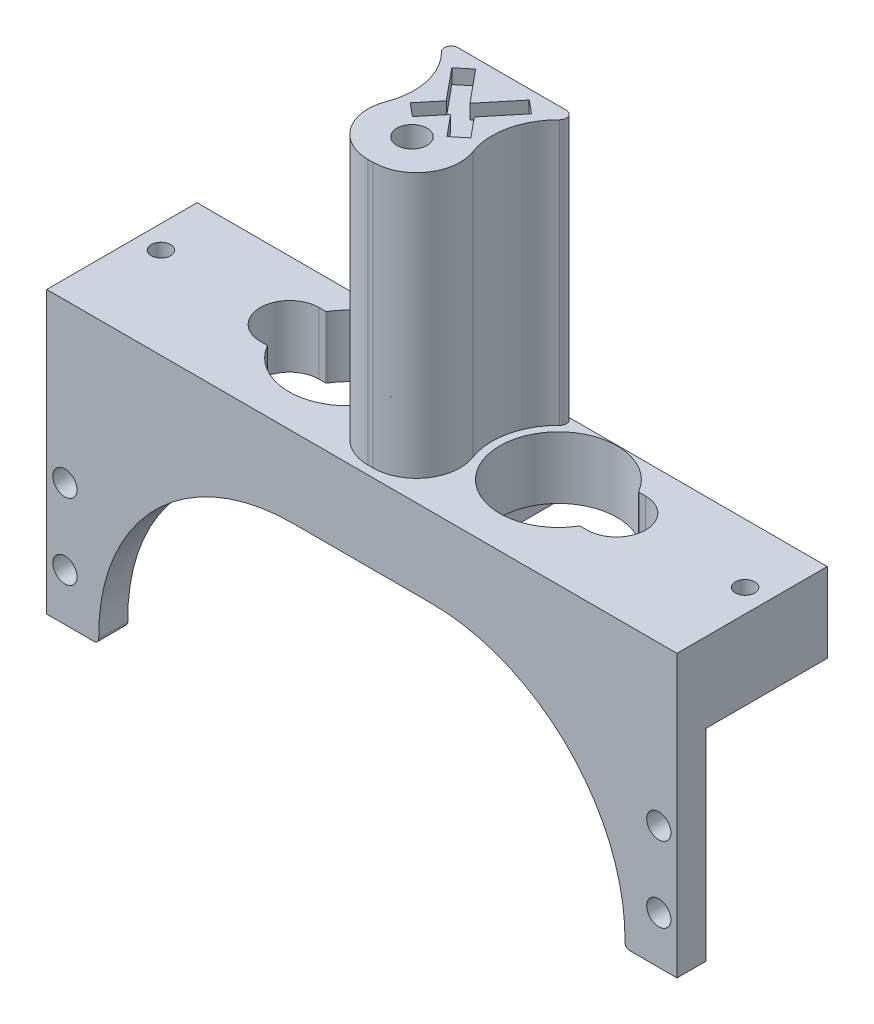
from build123d import *

# Parameters (mm, degrees)
BOSS_EXTRUDE1_START = -1.8
SKETCH1_R           = 1
BOSS_EXTRUDE1_DEPTH = 1.8
BOSS_EXTRUDE2_START = -1.8
SKETCH1_5_R         = 1
SKETCH1_5_W         = 23.35
SKETCH1_5_H         = 12.5
SKETCH1_5_W_2       = 0.2
SKETCH1_5_H_2       = 11.7
BOSS_EXTRUDE2_DEPTH = 6.4
SKETCH1_6_R         = 1
CUT_EXTRUDE9_DEPTH  = 5.25
SKETCH6_R           = 1.25
BOSS_EXTRUDE4_DEPTH = 3
CUT_EXTRUDE6_START  = -8.2
SKETCH4_6_R         = 1.55
CUT_EXTRUDE6_DEPTH  = 5.2
BOSS_EXTRUDE3_DEPTH = 27.3
CUT_EXTRUDE7_START  = -3
SKETCH4_7_R         = 1.55
CUT_EXTRUDE7_DEPTH  = 30.3
CUT_EXTRUDE8_DEPTH  = 1.5


with BuildPart() as part:
    # Sketch1 → Boss-Extrude1 (new body)
    with BuildSketch(Plane.XZ.offset(10.394345176).offset(BOSS_EXTRUDE1_START)):
        Polygon((-30.246052812, 14.536068682), (-30.246052812, -0.963931318), (-25.671052812, -0.963931318), (-25.671052812, 11.536068682), (-2.321052812, 11.536068682), (-2.321052812, -0.963931318), (6.828947188, -0.963931318), (6.828947188, 11.536068682), (30.178947188, 11.536068682), (30.178947188, -0.963931318), (34.753947188, -0.963931318), (34.753947188, 14.536068682), align=None)
        with Locations((-27.871052812, 5.136068682)):
            Circle(SKETCH1_R, mode=Mode.SUBTRACT)
        with Locations((32.378947188, 5.136068682)):
            Circle(SKETCH1_R, mode=Mode.SUBTRACT)
    extrude(amount=BOSS_EXTRUDE1_DEPTH)

    # Sketch1_5 → Boss-Extrude2 (add)
    with BuildSketch(Plane.XZ.offset(10.394345176).offset(BOSS_EXTRUDE2_START)):
        with BuildLine():
            Line((-30.246052812, 14.536068682), (-30.246052812, -0.963931318))
            Line((-30.246052812, -0.963931318), (-25.671052812, -0.963931318))
            Line((-25.671052812, -0.963931318), (-25.671052812, -0.713931318))
            Line((-25.671052812, -0.713931318), (-29.746052812, -0.713931318))
            ThreePointArc((-29.746052812, -0.713931318), (-29.922829508, -0.640708013), (-29.996052812, -0.463931318))
            Line((-29.996052812, -0.463931318), (-29.996052812, 4.511068682))
            Line((-29.996052812, 4.511068682), (-28.651677562, 4.511068682))
            ThreePointArc((-28.651677562, 4.511068682), (-28.871052812, 5.136068682), (-28.651677562, 5.761068682))
            Line((-28.651677562, 5.761068682), (-29.996052812, 5.761068682))
            Line((-29.996052812, 5.761068682), (-29.996052812, 10.736068682))
            ThreePointArc((-29.996052812, 10.736068682), (-29.922829508, 10.912845377), (-29.746052812, 10.986068682))
            Line((-29.746052812, 10.986068682), (-25.671052812, 10.986068682))
            Line((-25.671052812, 10.986068682), (-25.671052812, 11.536068682))
            Line((-25.671052812, 11.536068682), (-2.321052812, 11.536068682))
            Line((-2.321052812, 11.536068682), (-2.321052812, -0.963931318))
            Line((-2.321052812, -0.963931318), (6.828947188, -0.963931318))
            Line((6.828947188, -0.963931318), (6.828947188, 11.536068682))
            Line((6.828947188, 11.536068682), (30.178947188, 11.536068682))
            Line((30.178947188, 11.536068682), (30.178947188, -0.963931318))
            Line((30.178947188, -0.963931318), (34.753947188, -0.963931318))
            Line((34.753947188, -0.963931318), (34.753947188, 14.536068682))
            Line((34.753947188, 14.536068682), (2.253947188, 14.536068682))
            Line((2.253947188, 14.536068682), (-30.246052812, 14.536068682))
        make_face()
        with Locations((-0.121052812, 5.136068682)):
            Circle(SKETCH1_5_R, mode=Mode.SUBTRACT)
        with Locations((4.628947188, 5.136068682)):
            Circle(SKETCH1_5_R, mode=Mode.SUBTRACT)
        with Locations((32.378947188, 5.136068682)):
            Circle(SKETCH1_5_R, mode=Mode.SUBTRACT)
        with Locations((18.503947188, 5.286068682)):
            Rectangle(SKETCH1_5_W, SKETCH1_5_H)
        with BuildLine():
            Line((19.103947188, 2.111068682), (18.425821266, 2.111068682))
            ThreePointArc((18.425821266, 2.111068682), (18.376229436, 2.097905601), (18.339693232, 2.06188169))
            ThreePointArc((18.339693232, 2.06188169), (7.078947188, 5.136068682), (18.339693232, 8.210255674))
            ThreePointArc((18.339693232, 8.210255674), (18.376229436, 8.174231764), (18.425821266, 8.161068682))
            Line((18.425821266, 8.161068682), (19.103947188, 8.161068682))
            ThreePointArc((19.103947188, 8.161068682), (22.128947188, 5.136068682), (19.103947188, 2.111068682))
        make_face(mode=Mode.SUBTRACT)
        Polygon((-25.671052812, -0.713931318), (-25.671052812, -0.963931318), (-2.321052812, -0.963931318), (-2.321052812, 11.536068682), (-25.671052812, 11.536068682), (-25.671052812, 10.986068682), (-25.471052812, 10.986068682), (-25.471052812, -0.713931318), align=None)
        with BuildLine():
            ThreePointArc((-13.831798857, 2.06188169), (-13.868335061, 2.097905601), (-13.917926891, 2.111068682))
            Line((-13.917926891, 2.111068682), (-14.596052812, 2.111068682))
            ThreePointArc((-14.596052812, 2.111068682), (-17.621052812, 5.136068682), (-14.596052812, 8.161068682))
            Line((-14.596052812, 8.161068682), (-13.917926891, 8.161068682))
            ThreePointArc((-13.917926891, 8.161068682), (-13.868335061, 8.174231764), (-13.831798857, 8.210255674))
            ThreePointArc((-13.831798857, 8.210255674), (-2.571052812, 5.136068682), (-13.831798857, 2.06188169))
        make_face(mode=Mode.SUBTRACT)
        with BuildLine():
            Line((-29.746052812, -0.713931318), (-25.671052812, -0.713931318))
            Line((-25.671052812, -0.713931318), (-25.671052812, 10.986068682))
            Line((-25.671052812, 10.986068682), (-29.746052812, 10.986068682))
            ThreePointArc((-29.746052812, 10.986068682), (-29.922829508, 10.912845377), (-29.996052812, 10.736068682))
            Line((-29.996052812, 10.736068682), (-29.996052812, 5.761068682))
            Line((-29.996052812, 5.761068682), (-28.651677562, 5.761068682))
            ThreePointArc((-28.651677562, 5.761068682), (-27.539861591, 6.079632339), (-26.871052812, 5.136068682))
            ThreePointArc((-26.871052812, 5.136068682), (-27.539861591, 4.192505025), (-28.651677562, 4.511068682))
            Line((-28.651677562, 4.511068682), (-29.996052812, 4.511068682))
            Line((-29.996052812, 4.511068682), (-29.996052812, -0.463931318))
            ThreePointArc((-29.996052812, -0.463931318), (-29.922829508, -0.640708013), (-29.746052812, -0.713931318))
        make_face()
        with Locations((-25.571052812, 5.136068682)):
            Rectangle(SKETCH1_5_W_2, SKETCH1_5_H_2)
        with Locations((4.628947188, 5.136068682)):
            Circle(SKETCH1_5_R)
        with Locations((-0.121052812, 5.136068682)):
            Circle(SKETCH1_5_R)
    extrude(amount=-BOSS_EXTRUDE2_DEPTH)

    # Sketch1_6 → Cut-Extrude9 (cut)
    with BuildSketch(Plane.XZ.offset(10.394345176)):
        with Locations((4.628947188, 5.136068682)):
            Circle(SKETCH1_6_R)
        with Locations((-0.121052812, 5.136068682)):
            Circle(SKETCH1_6_R)
    extrude(amount=-CUT_EXTRUDE9_DEPTH, mode=Mode.SUBTRACT)

    # Sketch6 → Boss-Extrude4 (add)
    with BuildSketch(Plane.XY.offset(14.536068682)):
        with BuildLine():
            Line((34.753947188, -10.394345176), (9.394953593, -10.394345176))
            ThreePointArc((9.394953593, -10.394345176), (23.644922083, -16.360870979), (29.392610104, -30.700505374))
            ThreePointArc((29.392610104, -30.700505374), (29.532392174, -31.049241035), (29.878947188, -31.194345176))
            Line((29.878947188, -31.194345176), (34.753947188, -31.194345176))
            Line((34.753947188, -31.194345176), (34.753947188, -10.394345176))
        make_face()
        with Locations((32.878947188, -26.30759383)):
            Circle(SKETCH6_R, mode=Mode.SUBTRACT)
        with Locations((32.878947188, -18.534091138)):
            Circle(SKETCH6_R, mode=Mode.SUBTRACT)
        with BuildLine():
            Line((-4.887059217, -10.394345176), (-30.246052812, -10.394345176))
            Line((-30.246052812, -10.394345176), (-30.246052812, -16.729871547))
            Line((-30.246052812, -16.729871547), (-28.371052812, -15.647339792))
            Line((-28.371052812, -15.647339792), (-25.871052812, -17.090715465))
            Line((-25.871052812, -17.090715465), (-25.871052812, -19.977466811))
            Line((-25.871052812, -19.977466811), (-28.371052812, -21.420842484))
            Line((-28.371052812, -21.420842484), (-30.246052812, -20.338310729))
            Line((-30.246052812, -20.338310729), (-30.246052812, -24.503374239))
            Line((-30.246052812, -24.503374239), (-28.371052812, -23.420842484))
            Line((-28.371052812, -23.420842484), (-25.871052812, -24.864218157))
            Line((-25.871052812, -24.864218157), (-25.871052812, -27.750969503))
            Line((-25.871052812, -27.750969503), (-28.371052812, -29.194345176))
            Line((-28.371052812, -29.194345176), (-30.246052812, -28.111813421))
            Line((-30.246052812, -28.111813421), (-30.246052812, -31.194345176))
            Line((-30.246052812, -31.194345176), (-25.371052812, -31.194345176))
            ThreePointArc((-25.371052812, -31.194345176), (-25.024497799, -31.049241035), (-24.884715729, -30.700505374))
            ThreePointArc((-24.884715729, -30.700505374), (-19.137027708, -16.360870979), (-4.887059217, -10.394345176))
        make_face()
        Polygon((-28.371052812, -23.420842484), (-30.246052812, -24.503374239), (-30.246052812, -28.111813421), (-28.371052812, -29.194345176), (-25.871052812, -27.750969503), (-25.871052812, -24.864218157), align=None)
        with Locations((-28.371052812, -26.30759383)):
            Circle(SKETCH6_R, mode=Mode.SUBTRACT)
        Polygon((-28.371052812, -15.647339792), (-30.246052812, -16.729871547), (-30.246052812, -20.338310729), (-28.371052812, -21.420842484), (-25.871052812, -19.977466811), (-25.871052812, -17.090715465), align=None)
        with Locations((-28.371052812, -18.534091138)):
            Circle(SKETCH6_R, mode=Mode.SUBTRACT)
    extrude(amount=-BOSS_EXTRUDE4_DEPTH)

    # Sketch4_6 → Cut-Extrude6 (cut)
    with BuildSketch(Plane(origin=(0, -2.194345176, 0), x_dir=(1, 0, 0), z_dir=(0, 1, 0)).offset(CUT_EXTRUDE6_START)):
        Polygon((5.103947188, -11.010607671), (5.103947188, -7.719711137), (2.253947188, -6.07426287), (-0.596052812, -7.719711137), (-0.596052812, -11.010607671), (2.253947188, -12.656055938), align=None)
        with Locations((2.253947188, -9.365159404)):
            Circle(SKETCH4_6_R, mode=Mode.SUBTRACT)
        with Locations((2.253947188, -9.365159404)):
            Circle(SKETCH4_6_R)
    extrude(amount=CUT_EXTRUDE6_DEPTH, mode=Mode.SUBTRACT)

    # Sketch4 → Boss-Extrude3 (add)
    with BuildSketch(Plane(origin=(0, -2.194345176, 0), x_dir=(1, 0, 0), z_dir=(0, 1, 0))):
        with BuildLine():
            Line((1.993192449, -13.656055938), (2.514701927, -13.656055938))
            ThreePointArc((2.514701927, -13.656055938), (6.217553798, -11.71318089), (6.722992999, -7.562228392))
            ThreePointArc((6.722992999, -7.562228392), (6.440270151, -3.658198764), (8.34156903, -0.236730934))
            ThreePointArc((8.34156903, -0.236730934), (8.500600778, 0.528068047), (7.852347904, 0.963931318))
            Line((7.852347904, 0.963931318), (-3.344453529, 0.963931318))
            ThreePointArc((-3.344453529, 0.963931318), (-3.992706402, 0.528068047), (-3.833674654, -0.236730934))
            ThreePointArc((-3.833674654, -0.236730934), (-1.932375775, -3.658198764), (-2.215098624, -7.562228392))
            ThreePointArc((-2.215098624, -7.562228392), (-1.709659423, -11.71318089), (1.993192449, -13.656055938))
        make_face()
    extrude(amount=BOSS_EXTRUDE3_DEPTH)

    # Sketch4_7 → Cut-Extrude7 (cut)
    with BuildSketch(Plane(origin=(0, -2.194345176, 0), x_dir=(1, 0, 0), z_dir=(0, 1, 0)).offset(CUT_EXTRUDE7_START)):
        with Locations((2.253947188, -9.365159404)):
            Circle(SKETCH4_7_R)
    extrude(amount=CUT_EXTRUDE7_DEPTH, mode=Mode.SUBTRACT)

    # Sketch5 → Cut-Extrude8 (cut)
    with BuildSketch(Plane(origin=(0, 25.105654824, 0), x_dir=(1, 0, 0), z_dir=(0, 1, 0))):
        Polygon((5.385896038, -6.427447361), (3.697691675, -4.382517944), (6.366164089, -1.150185498), (5.016629458, -0.036068682), (2.253947188, -3.382517944), (-0.508735082, -0.036068682), (-1.858269713, -1.150185498), (0.8102027, -4.382517944), (-0.878001663, -6.427447361), (0.471532968, -7.541564177), (2.253947188, -5.382517944), (4.036361407, -7.541564177), align=None)
    extrude(amount=-CUT_EXTRUDE8_DEPTH, mode=Mode.SUBTRACT)


solid = part.part
